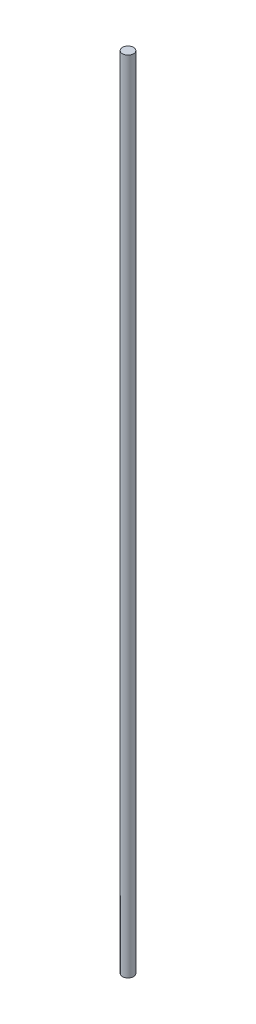
from build123d import *

# Parameters (mm, degrees)
BOSS_EXTRUDE1_DEPTH      = 457.2
BOSS_EXTRUDE1_DEPTH_BACK = 457.2
SKETCH1_R                = 6.35


with BuildPart() as part:
    # Sketch1 → Boss-Extrude1 (new, two sides: drawn at the far end of the back side and taken through both)
    with BuildSketch(Plane(origin=(0, 0, 0), x_dir=(1, 0, 0), z_dir=(0, 1, 0)).offset(-BOSS_EXTRUDE1_DEPTH_BACK)):
        Circle(SKETCH1_R)
    extrude(amount=BOSS_EXTRUDE1_DEPTH + BOSS_EXTRUDE1_DEPTH_BACK)


solid = part.part
